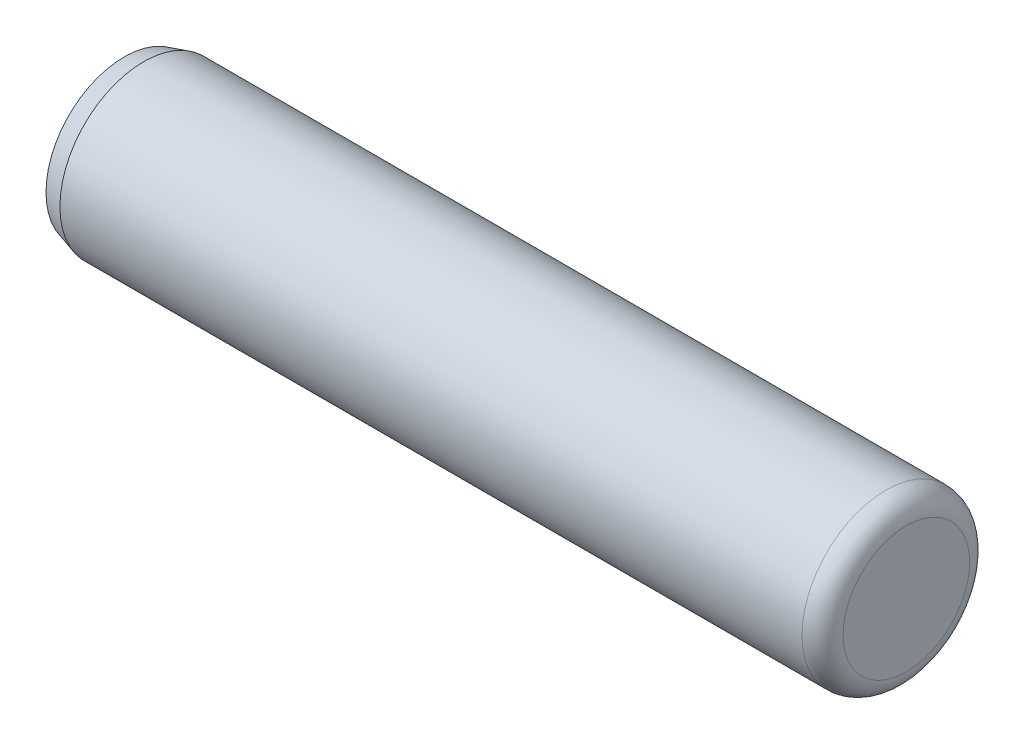
from build123d import *


with BuildPart() as part:
    # Sketch3 → Revolve1 (revolve)
    with BuildSketch(Plane.XY):
        with BuildLine():
            Line((11.1125, 1.79705), (11.1125, 0))
            Line((11.1125, 0), (-11.1125, 0))
            Line((-11.1125, 0), (-11.1125, 2.2225))
            Line((-11.1125, 2.2225), (-10.558872957, 2.38125))
            Line((-10.558872957, 2.38125), (10.5283, 2.38125))
            ThreePointArc((10.5283, 2.38125), (10.941391782, 2.210141782), (11.1125, 1.79705))
        make_face()
    revolve(axis=Axis((-11.1125, 0, 0), (1, 0, 0)))


solid = part.part
